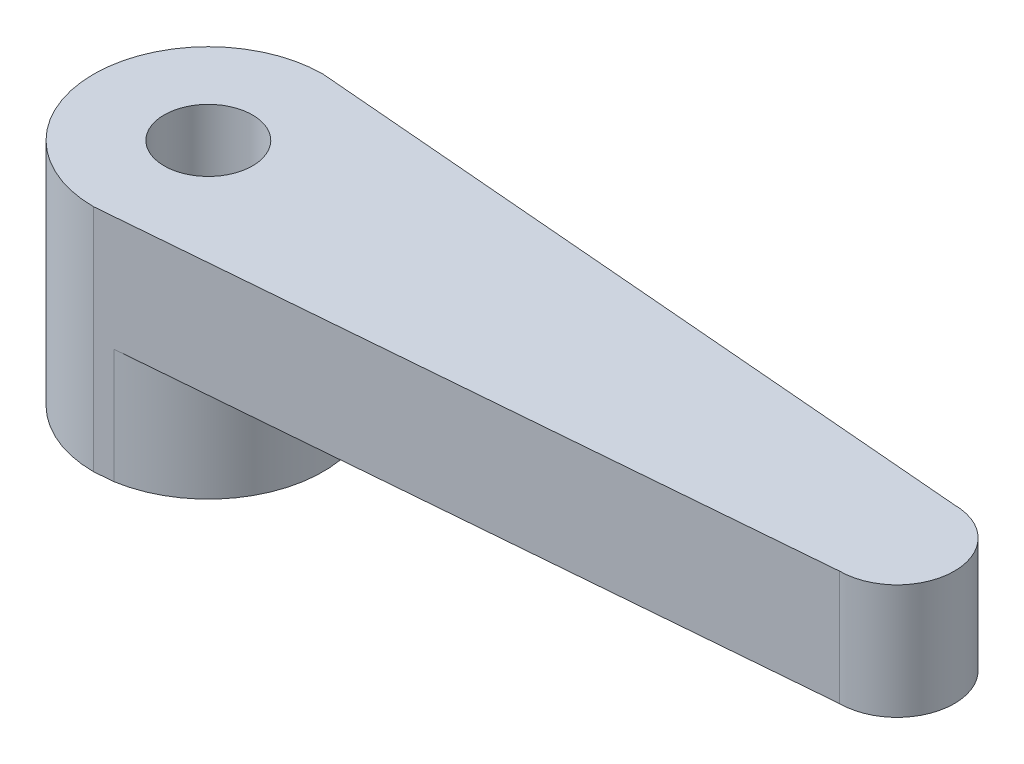
from build123d import *

# Parameters (mm, degrees)
SKETCH2_R           = 1.925
BOSS_EXTRUDE1_DEPTH = 5
BOSS_EXTRUDE2_START = -5
SKETCH2_3_R         = 1.925
BOSS_EXTRUDE2_DEPTH = 5


with BuildPart() as part:
    # Sketch2 → Boss-Extrude1 (new body)
    with BuildSketch(Plane(origin=(0, 0, 0), x_dir=(1, 0, 0), z_dir=(0, 1, 0))):
        with BuildLine():
            ThreePointArc((0, 5), (-5, 0), (0, -5))
            Line((0, -5), (30, -2.5))
            ThreePointArc((30, -2.5), (32.5, 0), (30, 2.5))
            Line((30, 2.5), (0, 5))
        make_face()
        Circle(SKETCH2_R, mode=Mode.SUBTRACT)
    extrude(amount=BOSS_EXTRUDE1_DEPTH)

    # Sketch2_3 → Boss-Extrude2 (add)
    with BuildSketch(Plane(origin=(0, 0, 0), x_dir=(1, 0, 0), z_dir=(0, 1, 0)).offset(BOSS_EXTRUDE2_START)):
        with BuildLine():
            Line((0.827586207, 4.931034483), (0, 5))
            ThreePointArc((0, 5), (-5, 0), (0, -5))
            Line((0, -5), (0.827586207, -4.931034483))
            ThreePointArc((0.827586207, -4.931034483), (3.816931427, -3.229711207), (5, 0))
            ThreePointArc((5, 0), (3.816931427, 3.229711207), (0.827586207, 4.931034483))
        make_face()
        Circle(SKETCH2_3_R, mode=Mode.SUBTRACT)
    extrude(amount=BOSS_EXTRUDE2_DEPTH)


solid = part.part
